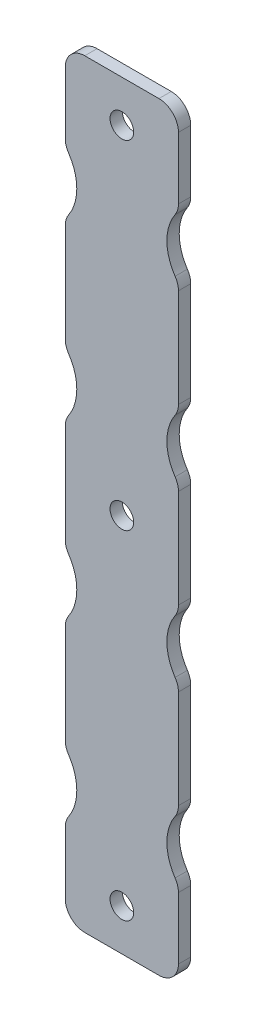
from build123d import *

# Parameters (mm, degrees)
SKETCH1_R           = 1.5367
BOSS_EXTRUDE1_DEPTH = 1.6
FILLET1_R           = 2.54
SKETCH3_R           = 1.5367
CUT_EXTRUDE1_DEPTH  = 2.6


with BuildPart() as part:
    # Sketch1 → Boss-Extrude1 (new body)
    with BuildSketch(Plane.XY):
        with BuildLine():
            Line((7.903015948, 75.005885785), (7.903015948, 68.549399108))
            ThreePointArc((7.903015948, 68.549399108), (9.403015948, 64.505885785), (7.903015948, 60.462372462))
            Line((7.903015948, 60.462372462), (7.903015948, 45.943399108))
            ThreePointArc((7.903015948, 45.943399108), (9.403015948, 41.899885785), (7.903015948, 37.856372462))
            Line((7.903015948, 37.856372462), (7.903015948, 23.337399108))
            ThreePointArc((7.903015948, 23.337399108), (9.403015948, 19.293885785), (7.903015948, 15.250372462))
            Line((7.903015948, 15.250372462), (7.903015948, 0.731399108))
            ThreePointArc((7.903015948, 0.731399108), (9.403015948, -3.312114215), (7.903015948, -7.355627538))
            Line((7.903015948, -7.355627538), (7.903015948, -13.812114215))
            Line((7.903015948, -13.812114215), (7.903015948, -18.812254411))
            Line((7.903015948, -18.812254411), (22.633015952, -18.812254411))
            Line((22.633015952, -18.812254411), (22.633015952, -13.812114215))
            Line((22.633015952, -13.812114215), (22.633015952, -7.355627538))
            ThreePointArc((22.633015952, -7.355627538), (21.133015952, -3.312114215), (22.633015952, 0.731399108))
            Line((22.633015952, 0.731399108), (22.633015952, 15.250372462))
            ThreePointArc((22.633015952, 15.250372462), (21.133015952, 19.293885785), (22.633015952, 23.337399108))
            Line((22.633015952, 23.337399108), (22.633015952, 37.856372462))
            ThreePointArc((22.633015952, 37.856372462), (21.133015952, 41.899885785), (22.633015952, 45.943399108))
            Line((22.633015952, 45.943399108), (22.633015952, 60.462372462))
            ThreePointArc((22.633015952, 60.462372462), (21.133015952, 64.505885785), (22.633015952, 68.549399108))
            Line((22.633015952, 68.549399108), (22.633015952, 75.005885785))
            Line((22.633015952, 75.005885785), (22.633015952, 80.006025981))
            Line((22.633015952, 80.006025981), (7.903015948, 80.006025981))
            Line((7.903015948, 80.006025981), (7.903015948, 75.005885785))
        make_face()
        with Locations((15.26801595, 74.583125981)):
            Circle(SKETCH1_R, mode=Mode.SUBTRACT)
        with Locations((15.26801595, -13.389354411)):
            Circle(SKETCH1_R, mode=Mode.SUBTRACT)
    extrude(amount=BOSS_EXTRUDE1_DEPTH)

    # Fillet1
    fillet1_edges = [part.edges().sort_by_distance(p)[0] for p in [
        (7.903015948, 80.006025981, 0.8),
        (22.633015952, 80.006025981, 0.8),
        (22.633015952, 68.549399108, 0.8),
        (22.633015952, 60.462372462, 0.8),
        (22.633015952, 45.943399108, 0.8),
        (22.633015952, 37.856372462, 0.8),
        (22.633015952, 23.337399108, 0.8),
        (22.633015952, 15.250372462, 0.8),
        (22.633015952, 0.731399108, 0.8),
        (22.633015952, -7.355627538, 0.8),
        (22.633015952, -18.812254411, 0.8),
        (7.903015948, -18.812254411, 0.8),
        (7.903015948, -7.355627538, 0.8),
        (7.903015948, 0.731399108, 0.8),
        (7.903015948, 15.250372462, 0.8),
        (7.903015948, 23.337399108, 0.8),
        (7.903015948, 37.856372462, 0.8),
        (7.903015948, 45.943399108, 0.8),
        (7.903015948, 60.462372462, 0.8),
        (7.903015948, 68.549399108, 0.8),
    ]]
    fillet(fillet1_edges, radius=FILLET1_R)

    # Sketch3 → Cut-Extrude1 (cut, through all)
    with BuildSketch(Plane.XY.offset(1.6)):
        with Locations((15.26801595, 30.596885785)):
            Circle(SKETCH3_R)
    extrude(amount=-CUT_EXTRUDE1_DEPTH, mode=Mode.SUBTRACT)


solid = part.part
